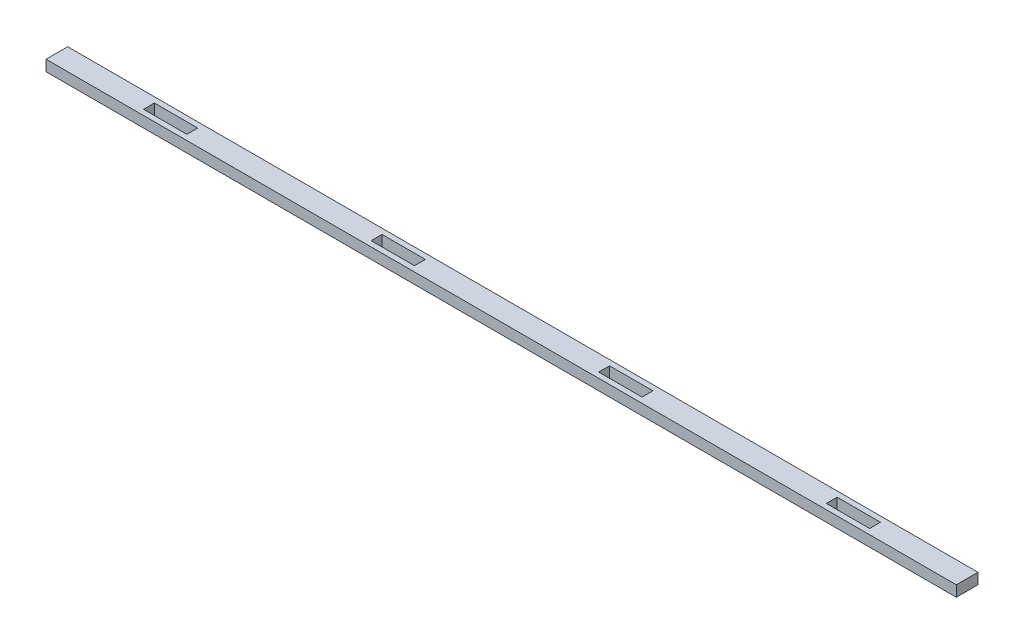
from build123d import *

# Parameters (mm, degrees)
SKETCH1_W           = 533.4
SKETCH1_H           = 12.7
BOSS_EXTRUDE1_DEPTH = 6.35
SKETCH2_W           = 25.4
SKETCH2_H           = 6.35
CUT_EXTRUDE1_DEPTH  = 7.35
LPATTERN1_COUNT     = 4
LPATTERN1_PITCH     = 133.35


with BuildPart() as part:
    # Sketch1 → Boss-Extrude1 (new body)
    with BuildSketch(Plane(origin=(0, 0, 0), x_dir=(1, 0, 0), z_dir=(0, 1, 0))):
        Rectangle(SKETCH1_W, SKETCH1_H)
    extrude(amount=BOSS_EXTRUDE1_DEPTH)

    # Sketch2 → Cut-Extrude1 (cut, through all)
    with BuildSketch(Plane(origin=(0, 6.35, 0), x_dir=(1, 0, 0), z_dir=(0, 1, 0))):
        with Locations((-200.025, 0)):
            Rectangle(SKETCH2_W, SKETCH2_H)
    cut_extrude1 = extrude(amount=-CUT_EXTRUDE1_DEPTH, mode=Mode.SUBTRACT)

    # LPattern1: Cut-Extrude1 ×4
    with Locations(*[(i * LPATTERN1_PITCH, 0, 0) for i in range(1, LPATTERN1_COUNT)]):
        add(cut_extrude1, mode=Mode.SUBTRACT)


solid = part.part
